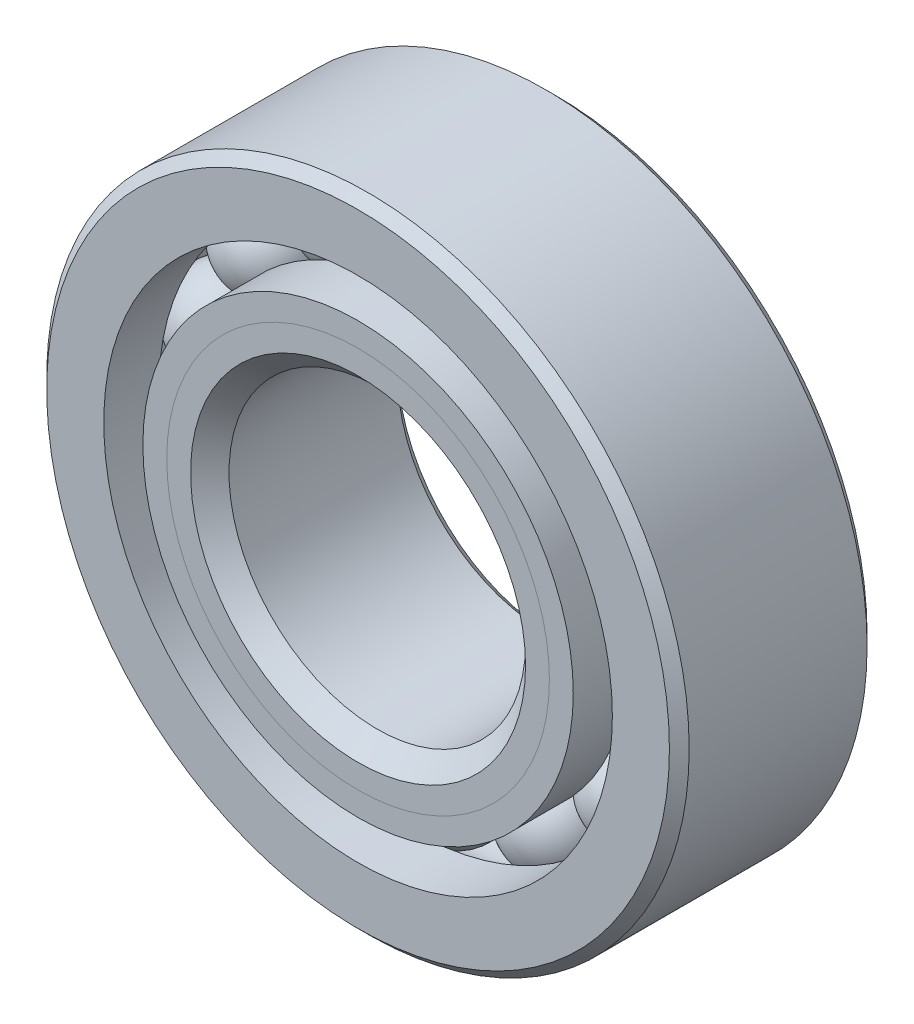
from build123d import *

# Parameters (mm, degrees)
CIRPATTERN1_COUNT = 14


with BuildPart() as part:
    # Sketch1 → Revolve1 (revolve)
    with BuildSketch(Plane(origin=(0, 0, 0), x_dir=(0, 0, -1), z_dir=(1, 0, 0)), mode=Mode.PRIVATE) as revolve1_sk:
        with BuildLine():
            Line((5.715, 20.6375), (-5.715, 20.6375))
            Line((-5.715, 20.6375), (-6.35, 20.0025))
            Line((-6.35, 20.0025), (-6.35, 16.337293956))
            Line((-6.35, 16.337293956), (-2.822222222, 16.337293956))
            ThreePointArc((-2.822222222, 16.337293956), (0, 18.170357426), (2.822222222, 16.337293956))
            Line((2.822222222, 16.337293956), (6.35, 16.337293956))
            Line((6.35, 16.337293956), (6.35, 20.0025))
            Line((6.35, 20.0025), (5.715, 20.6375))
        make_face()
    revolve(revolve1_sk.sketch.rotate(Axis((0, 0, 6.35), (0, 0, -1)), 90), axis=Axis((0, 0, 6.35), (0, 0, -1)))  # turned: the seam where the file's is


with BuildPart() as body_2:
    # Sketch2 → Revolve2 (revolve)
    with BuildSketch(Plane(origin=(0, 0, 0), x_dir=(0, 0, -1), z_dir=(1, 0, 0)), mode=Mode.PRIVATE) as revolve2_sk:
        with BuildLine():
            Line((-6.35, 13.825206044), (-2.822222222, 13.825206044))
            ThreePointArc((-2.822222222, 13.825206044), (-1.682636321, 12.490628511), (0, 11.992142574))
            Line((0, 11.992142574), (0, 10.758571287))
            Line((0, 10.758571287), (-4.816682621, 10.758571287))
            Line((-4.816682621, 10.758571287), (-6.35, 12.291888665))
            Line((-6.35, 12.291888665), (-6.35, 13.825206044))
        make_face()
    revolve(revolve2_sk.sketch.rotate(Axis((0, 0, 6.35), (0, 0, -1)), 90), axis=Axis((0, 0, 6.35), (0, 0, -1)))  # turned: the seam where the file's is


with BuildPart() as body_3:
    # Sketch3 → Revolve3 (revolve)
    with BuildSketch(Plane(origin=(0, 0, 0), x_dir=(0, 0, -1), z_dir=(1, 0, 0)), mode=Mode.PRIVATE) as revolve3_sk:
        with BuildLine():
            Line((-6.35, 12.291888665), (-4.816682621, 10.758571287))
            Line((-4.816682621, 10.758571287), (0, 10.758571287))
            Line((0, 10.758571287), (0, 11.992142574))
            ThreePointArc((0, 11.992142574), (1.682636321, 12.490628511), (2.822222222, 13.825206044))
            Line((2.822222222, 13.825206044), (6.35, 13.825206044))
            Line((6.35, 13.825206044), (6.35, 10.16))
            Line((6.35, 10.16), (5.715, 9.525))
            Line((5.715, 9.525), (-5.116428713, 9.525))
            Line((-5.116428713, 9.525), (-6.35, 10.758571287))
            Line((-6.35, 10.758571287), (-6.35, 12.291888665))
        make_face()
    revolve(revolve3_sk.sketch.rotate(Axis((0, 0, 6.35), (0, 0, -1)), 90), axis=Axis((0, 0, 6.35), (0, 0, -1)))  # turned: the seam where the file's is


with BuildPart() as body_4:
    # Sketch4 → Revolve4 (revolve)
    with BuildSketch(Plane(origin=(0, 0, 0), x_dir=(0, 0, -1), z_dir=(1, 0, 0))):
        with BuildLine():
            Line((-3.089107426, 15.08125), (3.089107426, 15.08125))
            ThreePointArc((3.089107426, 15.08125), (0, 18.170357426), (-3.089107426, 15.08125))
        make_face()
    revolve(axis=Axis((0, 15.08125, 3.089107426), (0, 0, -1)))


with BuildPart() as cirpattern1_1:
    # CirPattern1: pattern copy
    add(body_4.part.rotate(Axis((0, 0, 0), (0, 0, 1)), 1 * 360 / CIRPATTERN1_COUNT))


with BuildPart() as cirpattern1_2:
    # CirPattern1: pattern copy
    add(body_4.part.rotate(Axis((0, 0, 0), (0, 0, 1)), 2 * 360 / CIRPATTERN1_COUNT))


with BuildPart() as cirpattern1_3:
    # CirPattern1: pattern copy
    add(body_4.part.rotate(Axis((0, 0, 0), (0, 0, 1)), 3 * 360 / CIRPATTERN1_COUNT))


with BuildPart() as cirpattern1_4:
    # CirPattern1: pattern copy
    add(body_4.part.rotate(Axis((0, 0, 0), (0, 0, 1)), 4 * 360 / CIRPATTERN1_COUNT))


with BuildPart() as cirpattern1_5:
    # CirPattern1: pattern copy
    add(body_4.part.rotate(Axis((0, 0, 0), (0, 0, 1)), 5 * 360 / CIRPATTERN1_COUNT))


with BuildPart() as cirpattern1_6:
    # CirPattern1: pattern copy
    add(body_4.part.rotate(Axis((0, 0, 0), (0, 0, 1)), 6 * 360 / CIRPATTERN1_COUNT))


with BuildPart() as cirpattern1_7:
    # CirPattern1: pattern copy
    add(body_4.part.rotate(Axis((0, 0, 0), (0, 0, 1)), 7 * 360 / CIRPATTERN1_COUNT))


with BuildPart() as cirpattern1_8:
    # CirPattern1: pattern copy
    add(body_4.part.rotate(Axis((0, 0, 0), (0, 0, 1)), 8 * 360 / CIRPATTERN1_COUNT))


with BuildPart() as cirpattern1_9:
    # CirPattern1: pattern copy
    add(body_4.part.rotate(Axis((0, 0, 0), (0, 0, 1)), 9 * 360 / CIRPATTERN1_COUNT))


with BuildPart() as cirpattern1_10:
    # CirPattern1: pattern copy
    add(body_4.part.rotate(Axis((0, 0, 0), (0, 0, 1)), 10 * 360 / CIRPATTERN1_COUNT))


with BuildPart() as cirpattern1_11:
    # CirPattern1: pattern copy
    add(body_4.part.rotate(Axis((0, 0, 0), (0, 0, 1)), 11 * 360 / CIRPATTERN1_COUNT))


with BuildPart() as cirpattern1_12:
    # CirPattern1: pattern copy
    add(body_4.part.rotate(Axis((0, 0, 0), (0, 0, 1)), 12 * 360 / CIRPATTERN1_COUNT))


with BuildPart() as cirpattern1_13:
    # CirPattern1: pattern copy
    add(body_4.part.rotate(Axis((0, 0, 0), (0, 0, 1)), 13 * 360 / CIRPATTERN1_COUNT))


solid = Compound([part.part, body_2.part, body_3.part, body_4.part, cirpattern1_1.part, cirpattern1_2.part, cirpattern1_3.part, cirpattern1_4.part, cirpattern1_5.part, cirpattern1_6.part, cirpattern1_7.part, cirpattern1_8.part, cirpattern1_9.part, cirpattern1_10.part, cirpattern1_11.part, cirpattern1_12.part, cirpattern1_13.part])
